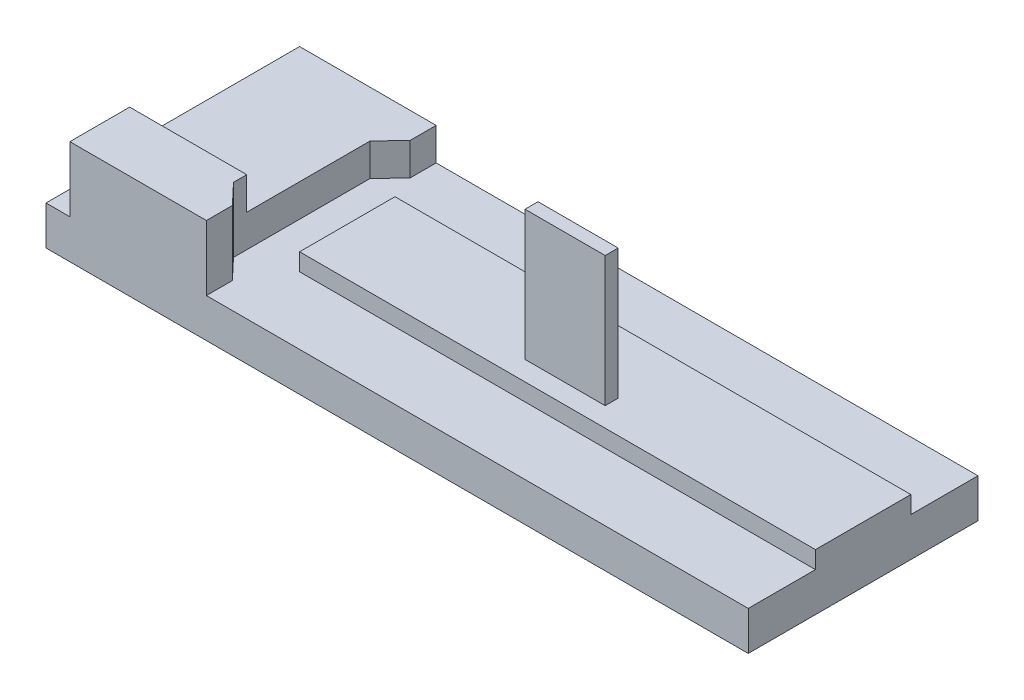
from build123d import *

# Parameters (mm, degrees)
SKETCH_1_W          = 162
SKETCH_1_H          = 53
EXTRUDE_1_DEPTH     = 9
EXTRUDE_2_DEPTH     = 15
SKETCH_5_W          = 39.196939595
SKETCH_5_H          = 7.5
CUT_EXTRUDE_1_DEPTH = 157.5
SKETCH_6_R          = 3.25
CUT_EXTRUDE_2_DEPTH = 15
SKETCH_7_W          = 119
SKETCH_7_H          = 22
EXTRUDE_3_DEPTH     = 4
SKETCH_8_W          = 18.5
SKETCH_8_H          = 3
EXTRUDE_4_DEPTH     = 30


with BuildPart() as part:
    # 草图1 → 凸台-拉伸1 (new body)
    with BuildSketch(Plane(origin=(0, 0, 0), x_dir=(1, 0, 0), z_dir=(0, 1, 0))):
        Rectangle(SKETCH_1_W, SKETCH_1_H)
    extrude(amount=EXTRUDE_1_DEPTH)

    # 草图2 → 凸台-拉伸2 (add)
    with BuildSketch(Plane(origin=(0, 9, 0), x_dir=(1, 0, 0), z_dir=(0, 1, 0))):
        Polygon((-75.5, 26.5), (-75.5, -26.5), (-44, -26.5), (-44, -20.5), (-48.5, -15.75), (-48.5, 15.75), (-44, 20.5), (-44, 26.5), align=None)
    extrude(amount=EXTRUDE_2_DEPTH)

    # 草图5 → 切除-拉伸1 (cut, through all)
    with BuildSketch(Plane.ZY.offset(75.5)):
        with Locations((-6.901530203, 20.25)):
            Rectangle(SKETCH_5_W, SKETCH_5_H)
    extrude(amount=-CUT_EXTRUDE_1_DEPTH, mode=Mode.SUBTRACT)

    # 草图6 → 切除-拉伸2 (cut)
    with BuildSketch(Plane.ZY.offset(75.5)):
        with Locations((19.598469797, 16.517563147)):
            Circle(SKETCH_6_R)
    extrude(amount=-CUT_EXTRUDE_2_DEPTH, mode=Mode.SUBTRACT)

    # 草图7 → 凸台-拉伸3 (add)
    with BuildSketch(Plane(origin=(0, 9, 0), x_dir=(1, 0, 0), z_dir=(0, 1, 0))):
        with Locations((21.5, 0)):
            Rectangle(SKETCH_7_W, SKETCH_7_H)
    extrude(amount=EXTRUDE_3_DEPTH)

    # 草图8 → 凸台-拉伸4 (add)
    with BuildSketch(Plane(origin=(0, 13, 0), x_dir=(1, 0, 0), z_dir=(0, 1, 0))):
        with Locations((18.75, -5)):
            Rectangle(SKETCH_8_W, SKETCH_8_H)
    extrude(amount=EXTRUDE_4_DEPTH)


solid = part.part
